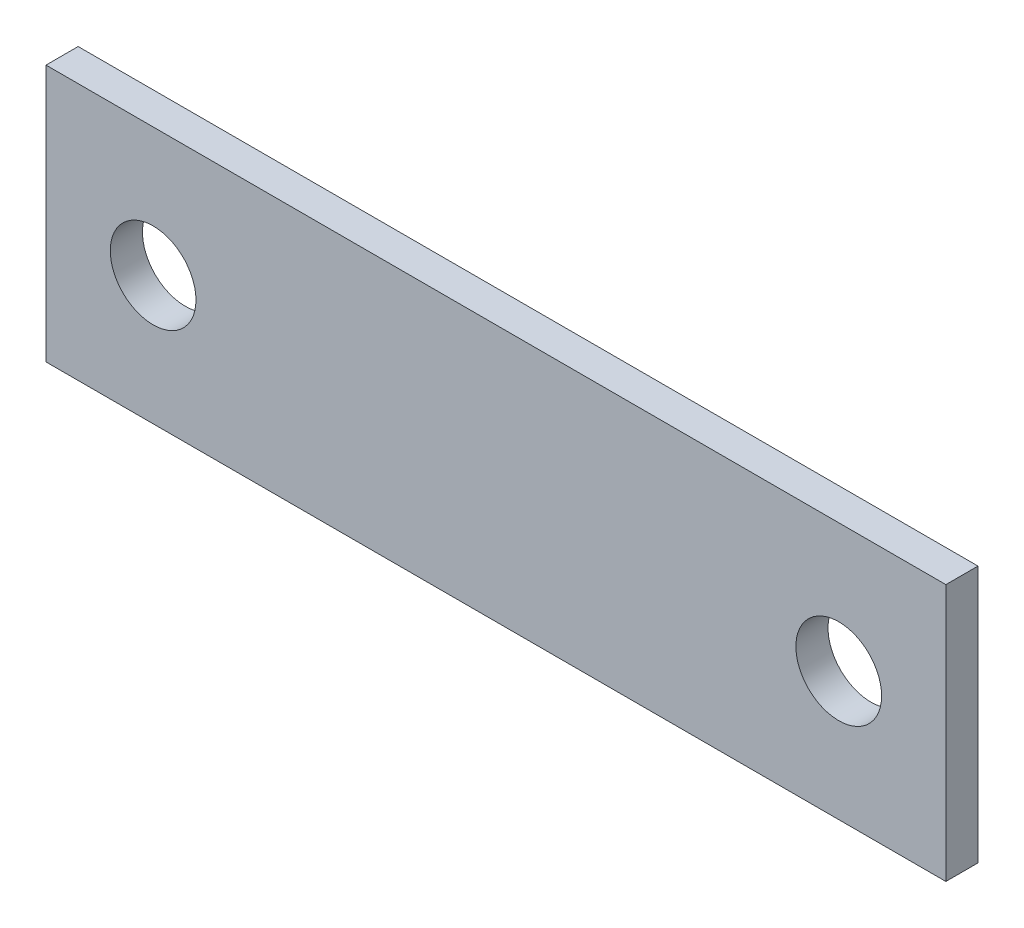
from build123d import *

# Parameters (mm, degrees)
SKETCH1_W           = 66.675
SKETCH1_H           = 19.05
SKETCH1_R           = 3.175
BOSS_EXTRUDE1_DEPTH = 2.38125


with BuildPart() as part:
    # Sketch1 → Boss-Extrude1 (new body)
    with BuildSketch(Plane.XY):
        Rectangle(SKETCH1_W, SKETCH1_H)
        with Locations((-25.4, 0)):
            Circle(SKETCH1_R, mode=Mode.SUBTRACT)
        with Locations((25.4, 0)):
            Circle(SKETCH1_R, mode=Mode.SUBTRACT)
    extrude(amount=BOSS_EXTRUDE1_DEPTH)


solid = part.part
